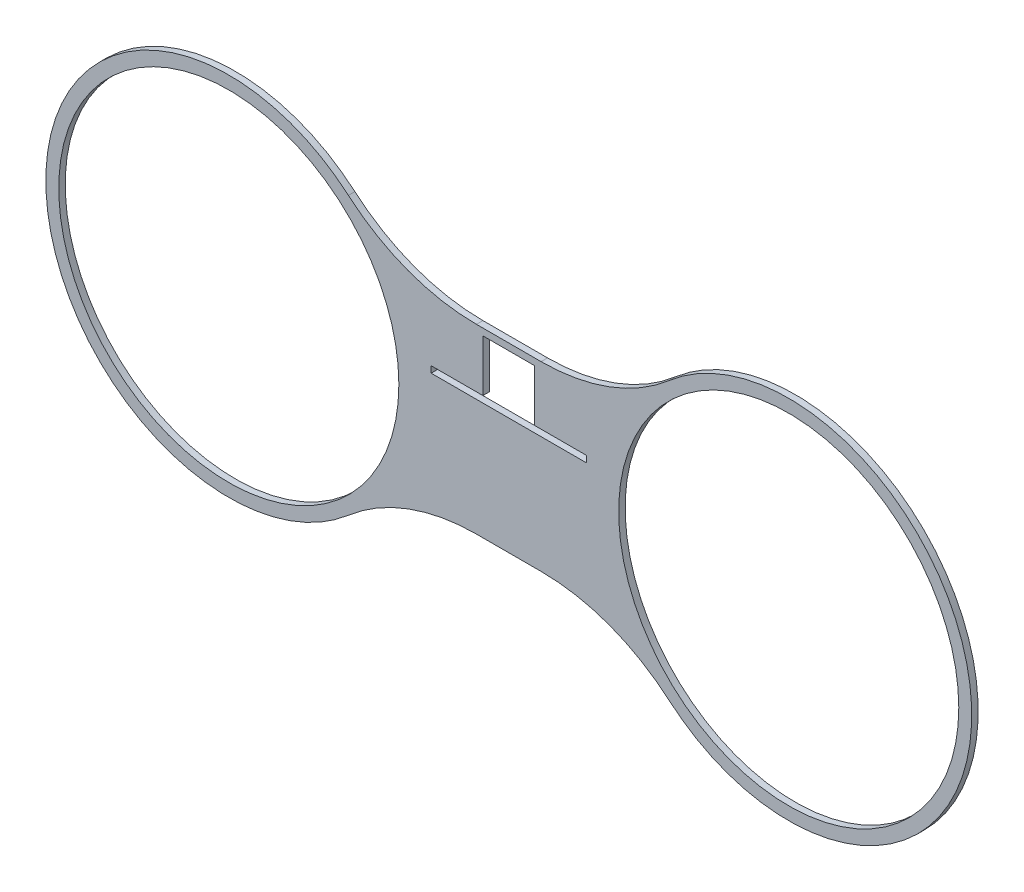
from build123d import *

# Parameters (mm, degrees)
SKETCH1_R           = 83.4771
SKETCH1_R_2         = 3.175
BOSS_EXTRUDE1_DEPTH = 3.175
SKETCH2_W           = 25.4
SKETCH2_H           = 25.4
CUT_EXTRUDE1_DEPTH  = 4.175
SKETCH3_W           = 76.2
SKETCH3_H           = 3.175
CUT_EXTRUDE2_DEPTH  = 4.175


with BuildPart() as part:
    # Sketch1 → Boss-Extrude1 (new body)
    with BuildSketch(Plane.XY):
        with BuildLine():
            Line((-15.854735322, -44.594342032), (15.852600775, -44.594342032))
            ThreePointArc((15.852600775, -44.594342032), (49.382027762, -50.630069264), (78.701832464, -67.979464917))
            ThreePointArc((78.701832464, -67.979464917), (227.246053, 0), (78.701832464, 67.979464917))
            ThreePointArc((78.701832464, 67.979464917), (49.382027762, 50.630069264), (15.852600775, 44.594342032))
            Line((15.852600775, 44.594342032), (-15.854735322, 44.594342032))
            ThreePointArc((-15.854735322, 44.594342032), (-49.384162309, 50.630069264), (-78.703967011, 67.979464917))
            ThreePointArc((-78.703967011, 67.979464917), (-227.248187547, 0), (-78.703967011, -67.979464917))
            ThreePointArc((-78.703967011, -67.979464917), (-49.384162309, -50.630069264), (-15.854735322, -44.594342032))
        make_face()
        with Locations((137.418953, 0)):
            Circle(SKETCH1_R, mode=Mode.SUBTRACT)
        with Locations((-137.421087547, 0)):
            Circle(SKETCH1_R, mode=Mode.SUBTRACT)
        with Locations((0, 28.575000036)):
            Circle(SKETCH1_R_2, mode=Mode.SUBTRACT)
    extrude(amount=BOSS_EXTRUDE1_DEPTH)

    # Sketch2 → Cut-Extrude1 (cut, through all)
    with BuildSketch(Plane.XY.offset(3.175)):
        with Locations((0, 28.575000036)):
            Rectangle(SKETCH2_W, SKETCH2_H)
    extrude(amount=-CUT_EXTRUDE1_DEPTH, mode=Mode.SUBTRACT)

    # Sketch3 → Cut-Extrude2 (cut, through all)
    with BuildSketch(Plane.XY.offset(3.175)):
        with Locations((0, 14.287500036)):
            Rectangle(SKETCH3_W, SKETCH3_H)
    extrude(amount=-CUT_EXTRUDE2_DEPTH, mode=Mode.SUBTRACT)


solid = part.part
